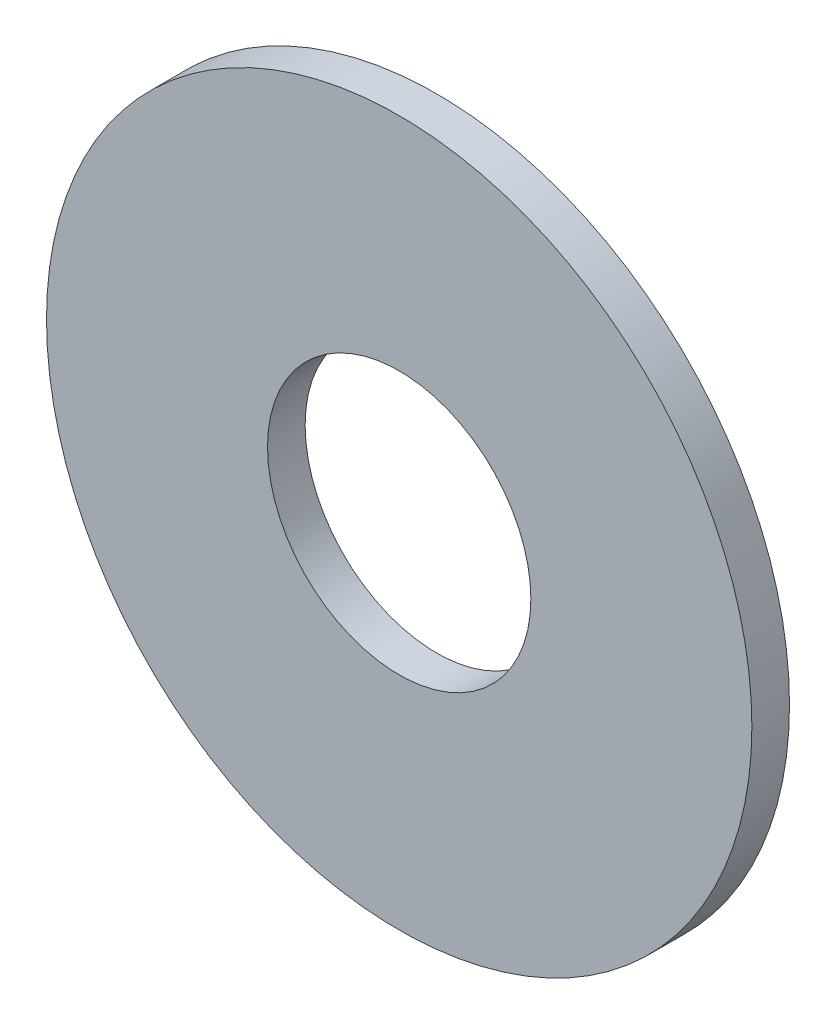
from build123d import *

# Parameters (mm, degrees)
SKETCH1_R      = 4.7625
SKETCH1_R_2    = 1.778
EXTRUDE1_DEPTH = 0.508


with BuildPart() as part:
    # Sketch1 → Extrude1 (new body)
    with BuildSketch(Plane.XY):
        Circle(SKETCH1_R)
        Circle(SKETCH1_R_2, mode=Mode.SUBTRACT)
    extrude(amount=-EXTRUDE1_DEPTH)


solid = part.part
